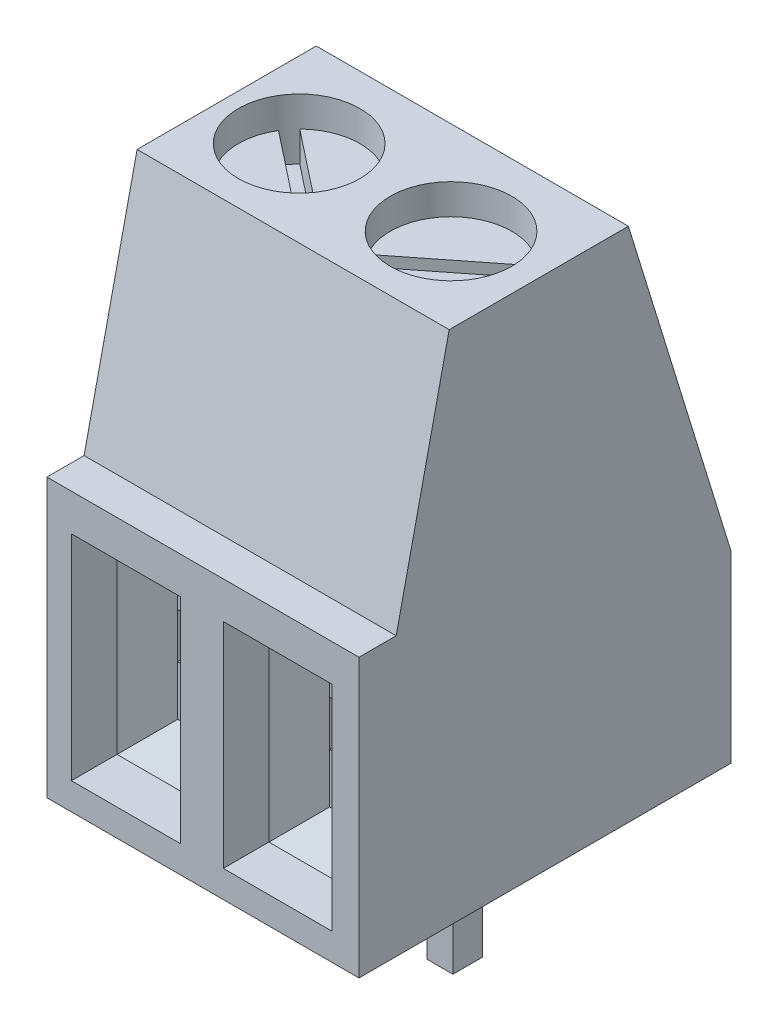
from build123d import *

# Parameters (mm, degrees)
SKETCH1_W          = 20.701
SKETCH1_H          = 6.223
EXTRUDE1_DEPTH     = 8.636
CUT_EXTRUDE1_DEPTH = 25.4
CUT_EXTRUDE2_DEPTH = 25.4
SKETCH4_R          = 1.016
CUT_EXTRUDE3_DEPTH = 0.508
CUT_EXTRUDE4_DEPTH = 0.508
SKETCH6_W          = 1.82195604
SKETCH6_H          = 3.576432228
CUT_EXTRUDE5_DEPTH = 1.27
CHAMFER1_SIZE      = 0.508
SKETCH7_W          = 0.80595604
SKETCH7_H          = 0.757943843
CUT_EXTRUDE6_DEPTH = 1.27
SKETCH8_W          = 0.433382436
SKETCH8_H          = 0.491166761
EXTRUDE2_DEPTH     = 1.905
SKETCH9_W          = 13.835725518
SKETCH9_H          = 11.068580414
CUT_EXTRUDE7_DEPTH = 25.4
SKETCH10_W         = 3.388588983
SKETCH10_H         = 10.514703946
CUT_EXTRUDE8_DEPTH = 25.4


with BuildPart() as part:
    # Sketch1 → Extrude1 (new body)
    with BuildSketch(Plane(origin=(0, 0, 0), x_dir=(1, 0, 0), z_dir=(0, 1, 0))):
        with Locations((10.3505, 3.1115)):
            Rectangle(SKETCH1_W, SKETCH1_H)
    extrude(amount=EXTRUDE1_DEPTH)

    # Sketch2 → Cut-Extrude1 (cut)
    with BuildSketch(Plane(origin=(20.701, 0, 0), x_dir=(0, 0, -1), z_dir=(1, 0, 0))):
        Polygon((-2.869110069, 4.645946632), (0.62179162, 4.645946632), (2.217632392, 11.827230107), (-2.869110069, 11.827230107), align=None)
    extrude(amount=-CUT_EXTRUDE1_DEPTH, mode=Mode.SUBTRACT)

    # Sketch3 → Cut-Extrude2 (cut)
    with BuildSketch(Plane(origin=(20.701, 0, 0), x_dir=(0, 0, -1), z_dir=(1, 0, 0))):
        Polygon((4.012953261, 10.231389335), (6.905414661, 0.855824797), (9.199435771, 0.855824797), (9.199435771, 10.231389335), align=None)
    extrude(amount=-CUT_EXTRUDE2_DEPTH, mode=Mode.SUBTRACT)

    # Sketch4 → Cut-Extrude3 (cut)
    with BuildSketch(Plane(origin=(0, 8.636, 0), x_dir=(1, 0, 0), z_dir=(0, 1, 0))):
        with Locations((1.27, 2.949100672)):
            Circle(SKETCH4_R)
        with Locations((3.81, 2.949100672)):
            Circle(SKETCH4_R)
        with Locations((6.35, 2.949100672)):
            Circle(SKETCH4_R)
        with Locations((8.89, 2.949100672)):
            Circle(SKETCH4_R)
        with Locations((11.43, 2.949100672)):
            Circle(SKETCH4_R)
        with Locations((13.97, 2.949100672)):
            Circle(SKETCH4_R)
        with Locations((16.51, 2.949100672)):
            Circle(SKETCH4_R)
        with Locations((19.05, 2.949100672)):
            Circle(SKETCH4_R)
    extrude(amount=-CUT_EXTRUDE3_DEPTH, mode=Mode.SUBTRACT)

    # Sketch5 → Cut-Extrude4 (cut)
    with BuildSketch(Plane(origin=(0, 8.128, 0), x_dir=(1, 0, 0), z_dir=(0, 1, 0))):
        with BuildLine():
            ThreePointArc((0.55685802, 3.67276117), (0.471993814, 3.577942566), (0.399647546, 3.473259623))
            Line((0.399647546, 3.473259623), (1.98314198, 2.225440174))
            ThreePointArc((1.98314198, 2.225440174), (2.068006186, 2.320258778), (2.140352454, 2.42494172))
            Line((2.140352454, 2.42494172), (0.55685802, 3.67276117))
        make_face()
        with BuildLine():
            ThreePointArc((2.939647546, 2.42494172), (3.011993814, 2.320258778), (3.09685802, 2.225440174))
            Line((3.09685802, 2.225440174), (4.680352454, 3.473259623))
            ThreePointArc((4.680352454, 3.473259623), (4.608006186, 3.577942566), (4.52314198, 3.67276117))
            Line((4.52314198, 3.67276117), (2.939647546, 2.42494172))
        make_face()
        with BuildLine():
            ThreePointArc((5.34196875, 3.076100672), (5.334, 2.949100672), (5.34196875, 2.822100672))
            Line((5.34196875, 2.822100672), (7.35803125, 2.822100672))
            ThreePointArc((7.35803125, 2.822100672), (7.364005855, 2.885475793), (7.366, 2.949100672))
            ThreePointArc((7.366, 2.949100672), (7.364005855, 3.012725551), (7.35803125, 3.076100672))
            Line((7.35803125, 3.076100672), (5.34196875, 3.076100672))
        make_face()
        with BuildLine():
            ThreePointArc((8.458529789, 2.041483422), (8.576688012, 1.994233554), (8.699870069, 1.9622946))
            Line((8.699870069, 1.9622946), (9.321470211, 3.856717921))
            ThreePointArc((9.321470211, 3.856717921), (9.203311988, 3.90396779), (9.080129931, 3.935906744))
            Line((9.080129931, 3.935906744), (8.458529789, 2.041483422))
        make_face()
        with BuildLine():
            ThreePointArc((11.557, 3.957131921), (11.43, 3.965100672), (11.303, 3.957131921))
            Line((11.303, 3.957131921), (11.303, 1.941069422))
            ThreePointArc((11.303, 1.941069422), (11.43, 1.933100672), (11.557, 1.941069422))
            Line((11.557, 1.941069422), (11.557, 3.957131921))
        make_face()
        with BuildLine():
            ThreePointArc((13.060727808, 3.402399778), (13.011197076, 3.285185412), (12.976706622, 3.162699047))
            Line((12.976706622, 3.162699047), (14.879272192, 2.495801565))
            ThreePointArc((14.879272192, 2.495801565), (14.928802924, 2.613015931), (14.963293378, 2.735502296))
            Line((14.963293378, 2.735502296), (13.060727808, 3.402399778))
        make_face()
        with BuildLine():
            ThreePointArc((16.944941036, 3.867295801), (16.826755289, 3.914461789), (16.703600756, 3.946484624))
            Line((16.703600756, 3.946484624), (16.075058964, 2.030905542))
            ThreePointArc((16.075058964, 2.030905542), (16.193244711, 1.983739555), (16.316399244, 1.95171672))
            Line((16.316399244, 1.95171672), (16.944941036, 3.867295801))
        make_face()
        with BuildLine():
            ThreePointArc((18.349819557, 3.662547267), (18.264852019, 3.567810091), (18.192609083, 3.463045721))
            Line((18.192609083, 3.463045721), (19.750180443, 2.235654077))
            ThreePointArc((19.750180443, 2.235654077), (19.835147981, 2.330391253), (19.907390917, 2.435155623))
            Line((19.907390917, 2.435155623), (18.349819557, 3.662547267))
        make_face()
    extrude(amount=-CUT_EXTRUDE4_DEPTH, mode=Mode.SUBTRACT)

    # Sketch6 → Cut-Extrude5 (cut)
    with BuildSketch(Plane.XY):
        with Locations((3.861070401, 2.24061075)):
            Rectangle(SKETCH6_W, SKETCH6_H)
        with Locations((1.321070401, 2.24061075)):
            Rectangle(SKETCH6_W, SKETCH6_H)
        with Locations((6.401070401, 2.24061075)):
            Rectangle(SKETCH6_W, SKETCH6_H)
        with Locations((8.941070401, 2.24061075)):
            Rectangle(SKETCH6_W, SKETCH6_H)
        with Locations((11.481070401, 2.24061075)):
            Rectangle(SKETCH6_W, SKETCH6_H)
        with Locations((14.021070401, 2.24061075)):
            Rectangle(SKETCH6_W, SKETCH6_H)
        with Locations((16.561070401, 2.24061075)):
            Rectangle(SKETCH6_W, SKETCH6_H)
        with Locations((19.101070401, 2.24061075)):
            Rectangle(SKETCH6_W, SKETCH6_H)
    extrude(amount=-CUT_EXTRUDE5_DEPTH, mode=Mode.SUBTRACT)

    # Chamfer1
    chamfer1_edges = [part.edges().sort_by_distance(p)[0] for p in [
        (0.410092381, 2.24061075, -1.27),
        (1.321070401, 4.028826864, -1.27),
        (2.232048421, 2.24061075, -1.27),
        (1.321070401, 0.452394636, -1.27),
        (3.861070401, 4.028826864, -1.27),
        (4.772048421, 2.24061075, -1.27),
        (3.861070401, 0.452394636, -1.27),
        (2.950092381, 2.24061075, -1.27),
        (6.401070401, 4.028826864, -1.27),
        (7.312048421, 2.24061075, -1.27),
        (6.401070401, 0.452394636, -1.27),
        (5.490092381, 2.24061075, -1.27),
        (8.941070401, 4.028826864, -1.27),
        (9.852048421, 2.24061075, -1.27),
        (8.941070401, 0.452394636, -1.27),
        (8.030092381, 2.24061075, -1.27),
        (11.481070401, 4.028826864, -1.27),
        (12.392048421, 2.24061075, -1.27),
        (11.481070401, 0.452394636, -1.27),
        (10.570092381, 2.24061075, -1.27),
        (14.021070401, 4.028826864, -1.27),
        (14.932048421, 2.24061075, -1.27),
        (14.021070401, 0.452394636, -1.27),
        (13.110092381, 2.24061075, -1.27),
        (16.561070401, 4.028826864, -1.27),
        (17.472048421, 2.24061075, -1.27),
        (16.561070401, 0.452394636, -1.27),
        (15.650092381, 2.24061075, -1.27),
        (19.101070401, 4.028826864, -1.27),
        (20.012048421, 2.24061075, -1.27),
        (19.101070401, 0.452394636, -1.27),
        (18.190092381, 2.24061075, -1.27),
    ]]
    chamfer(chamfer1_edges, length=CHAMFER1_SIZE)

    # Sketch7 → Cut-Extrude6 (cut)
    with BuildSketch(Plane.XY.offset(-1.27)):
        with Locations((1.321070401, 2.17271271)):
            Rectangle(SKETCH7_W, SKETCH7_H)
        with Locations((3.861070401, 2.17271271)):
            Rectangle(SKETCH7_W, SKETCH7_H)
        with Locations((6.401070401, 2.17271271)):
            Rectangle(SKETCH7_W, SKETCH7_H)
        with Locations((8.941070401, 2.17271271)):
            Rectangle(SKETCH7_W, SKETCH7_H)
        with Locations((11.481070401, 2.17271271)):
            Rectangle(SKETCH7_W, SKETCH7_H)
        with Locations((14.021070401, 2.17271271)):
            Rectangle(SKETCH7_W, SKETCH7_H)
        with Locations((16.561070401, 2.17271271)):
            Rectangle(SKETCH7_W, SKETCH7_H)
        with Locations((19.101070401, 2.17271271)):
            Rectangle(SKETCH7_W, SKETCH7_H)
    extrude(amount=-CUT_EXTRUDE6_DEPTH, mode=Mode.SUBTRACT)

    # Sketch8 → Extrude2 (add)
    with BuildSketch(Plane.XZ):
        with Locations((3.829530977, -2.990246105)):
            Rectangle(SKETCH8_W, SKETCH8_H)
        with Locations((1.289530977, -2.990246105)):
            Rectangle(SKETCH8_W, SKETCH8_H)
        with Locations((6.369530977, -2.990246105)):
            Rectangle(SKETCH8_W, SKETCH8_H)
        with Locations((8.909530977, -2.990246105)):
            Rectangle(SKETCH8_W, SKETCH8_H)
        with Locations((11.449530977, -2.990246105)):
            Rectangle(SKETCH8_W, SKETCH8_H)
        with Locations((13.989530977, -2.990246105)):
            Rectangle(SKETCH8_W, SKETCH8_H)
        with Locations((16.529530977, -2.990246105)):
            Rectangle(SKETCH8_W, SKETCH8_H)
        with Locations((19.069530977, -2.990246105)):
            Rectangle(SKETCH8_W, SKETCH8_H)
    extrude(amount=EXTRUDE2_DEPTH)

    # Sketch9 → Cut-Extrude7 (cut)
    with BuildSketch(Plane(origin=(0, 8.636, 0), x_dir=(1, 0, 0), z_dir=(0, 1, 0))):
        with Locations((14.474610491, 2.472928053)):
            Rectangle(SKETCH9_W, SKETCH9_H)
    extrude(amount=-CUT_EXTRUDE7_DEPTH, mode=Mode.SUBTRACT)

    # Sketch10 → Cut-Extrude8 (cut)
    with BuildSketch(Plane(origin=(0, 8.636, 0), x_dir=(1, 0, 0), z_dir=(0, 1, 0))):
        with Locations((6.914242224, 3.1115)):
            Rectangle(SKETCH10_W, SKETCH10_H)
    extrude(amount=-CUT_EXTRUDE8_DEPTH, mode=Mode.SUBTRACT)


solid = part.part
